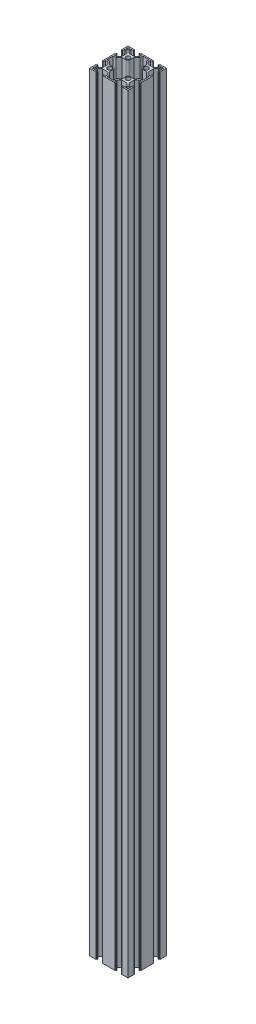
from build123d import *

# Parameters (mm, degrees)
SKETCH1_W                = 60
SKETCH1_H                = 60
BOSS_EXTRUDE1_DEPTH      = 1200
CUT_EXTRUDE1_DEPTH       = 1201.749765771
CIRPATTERN1_COUNT        = 4
CIRPATTERN1_COPY_1_DEPTH = 1201.749765771
CIRPATTERN1_COPY_2_DEPTH = 1201.749765771
CIRPATTERN1_COPY_3_DEPTH = 1201.749765771
SKETCH4_R                = 3.4
CUT_EXTRUDE2_DEPTH       = 1201.749765771
FILLET1_R                = 0.2
FILLET2_R                = 0.2
FILLET3_R                = 0.2
FILLET4_R                = 0.2


with BuildPart() as part:
    # Sketch1 → Boss-Extrude1 (new body)
    with BuildSketch(Plane(origin=(0, 0, 0), x_dir=(1, 0, 0), z_dir=(0, 1, 0))):
        Rectangle(SKETCH1_W, SKETCH1_H)
        Polygon((-23.05, -28), (-6.95, -28), (-6.95, -24.4), (-10.615, -20.8), (-19.385, -20.8), (-23.05, -24.4), align=None, mode=Mode.SUBTRACT)
        Polygon((10.615, -20.8), (19.385, -20.8), (23.05, -24.4), (23.05, -28), (6.95, -28), (6.95, -24.4), align=None, mode=Mode.SUBTRACT)
        Polygon((19.385, 20.8), (23.05, 24.4), (23.05, 28), (6.95, 28), (6.95, 24.4), (10.615, 20.8), align=None, mode=Mode.SUBTRACT)
        Polygon((-23.05, 24.4), (-23.05, 28), (-6.95, 28), (-6.95, 24.4), (-10.615, 20.8), (-19.385, 20.8), align=None, mode=Mode.SUBTRACT)
        Polygon((-20.8, 19.385), (-24.4, 23.05), (-28, 23.05), (-28, 6.95), (-24.4, 6.95), (-20.8, 10.615), align=None, mode=Mode.SUBTRACT)
        Polygon((-24.4, -23.05), (-28, -23.05), (-28, -6.95), (-24.4, -6.95), (-20.8, -10.615), (-20.8, -19.385), align=None, mode=Mode.SUBTRACT)
        Polygon((20.8, -19.385), (24.4, -23.05), (28, -23.05), (28, -6.95), (24.4, -6.95), (20.8, -10.615), align=None, mode=Mode.SUBTRACT)
        Polygon((24.4, 23.05), (28, 23.05), (28, 6.95), (24.4, 6.95), (20.8, 10.615), (20.8, 19.385), align=None, mode=Mode.SUBTRACT)
    extrude(amount=BOSS_EXTRUDE1_DEPTH)

    # Sketch2 → Cut-Extrude1 (cut, through all)
    with BuildSketch(Plane(origin=(0, 1200, 0), x_dir=(1, 0, 0), z_dir=(0, 1, 0))):
        Polygon((-19.1, -28), (-19.1, -29), (-20.1, -29), (-20.1, -30), (-9.9, -30), (-9.9, -29), (-10.9, -29), (-10.9, -28), align=None)
    cut_extrude1 = extrude(amount=-CUT_EXTRUDE1_DEPTH, mode=Mode.SUBTRACT)

    # Mirror1: Cut-Extrude1 across plane
    add(cut_extrude1.mirror(Plane(origin=(0, 0, 0), x_dir=(0, 0, 1), z_dir=(1, 0, 0))), mode=Mode.SUBTRACT)

    # CirPattern1: Cut-Extrude1 ×4 about axis
    cirpattern1_axis = Axis((0, 1050, 0), (0, -1, 0))
    for i in range(1, CIRPATTERN1_COUNT):
        add(cut_extrude1.rotate(cirpattern1_axis, i * 360 / CIRPATTERN1_COUNT), mode=Mode.SUBTRACT)

    # CirPattern1 copy 1 sketch → CirPattern1 copy 1 (cut, through all)
    with BuildSketch(Plane(origin=(0, 1200, 0), x_dir=(0, 0, -1), z_dir=(0, 1, 0))):
        Polygon((-19.1, 28), (-19.1, 29), (-20.1, 29), (-20.1, 30), (-9.9, 30), (-9.9, 29), (-10.9, 29), (-10.9, 28), align=None)
    extrude(amount=-CIRPATTERN1_COPY_1_DEPTH, mode=Mode.SUBTRACT)

    # CirPattern1 copy 2 sketch → CirPattern1 copy 2 (cut, through all)
    with BuildSketch(Plane(origin=(0, 1200, 0), x_dir=(1, 0, 0), z_dir=(0, 1, 0))):
        Polygon((-19.1, 28), (-19.1, 29), (-20.1, 29), (-20.1, 30), (-9.9, 30), (-9.9, 29), (-10.9, 29), (-10.9, 28), align=None)
    extrude(amount=-CIRPATTERN1_COPY_2_DEPTH, mode=Mode.SUBTRACT)

    # CirPattern1 copy 3 sketch → CirPattern1 copy 3 (cut, through all)
    with BuildSketch(Plane.ZX.offset(1200)):
        Polygon((-19.1, 28), (-19.1, 29), (-20.1, 29), (-20.1, 30), (-9.9, 30), (-9.9, 29), (-10.9, 29), (-10.9, 28), align=None)
    extrude(amount=-CIRPATTERN1_COPY_3_DEPTH, mode=Mode.SUBTRACT)

    # Sketch4 → Cut-Extrude2 (cut, through all)
    with BuildSketch(Plane(origin=(0, 1200, 0), x_dir=(1, 0, 0), z_dir=(0, 1, 0))):
        with BuildLine():
            Line((-13.197035349, 9.797035349), (-18.8, 9.797035349))
            Line((-18.8, 9.797035349), (-23.561071557, 4.95))
            Line((-23.561071557, 4.95), (-28, 4.95))
            Line((-28, 4.95), (-28, -4.95))
            Line((-28, -4.95), (-23.561071557, -4.95))
            Line((-23.561071557, -4.95), (-18.8, -9.797035349))
            Line((-18.8, -9.797035349), (-13.197035349, -9.797035349))
            ThreePointArc((-13.197035349, -9.797035349), (-10.792872293, -10.792872293), (-9.797035349, -13.197035349))
            Line((-9.797035349, -13.197035349), (-9.797035349, -18.8))
            Line((-9.797035349, -18.8), (-4.95, -23.561071557))
            Line((-4.95, -23.561071557), (-4.95, -28))
            Line((-4.95, -28), (4.95, -28))
            Line((4.95, -28), (4.95, -23.561071557))
            Line((4.95, -23.561071557), (9.797035349, -18.8))
            Line((9.797035349, -18.8), (9.797035349, -13.197035349))
            ThreePointArc((9.797035349, -13.197035349), (10.792872293, -10.792872293), (13.197035349, -9.797035349))
            Line((13.197035349, -9.797035349), (18.8, -9.797035349))
            Line((18.8, -9.797035349), (23.561071557, -4.95))
            Line((23.561071557, -4.95), (28, -4.95))
            Line((28, -4.95), (28, 4.95))
            Line((28, 4.95), (23.561071557, 4.95))
            Line((23.561071557, 4.95), (18.8, 9.797035349))
            Line((18.8, 9.797035349), (13.197035349, 9.797035349))
            ThreePointArc((13.197035349, 9.797035349), (10.792872293, 10.792872293), (9.797035349, 13.197035349))
            Line((9.797035349, 13.197035349), (9.797035349, 18.8))
            Line((9.797035349, 18.8), (4.95, 23.561071557))
            Line((4.95, 23.561071557), (4.95, 28))
            Line((4.95, 28), (-4.95, 28))
            Line((-4.95, 28), (-4.95, 23.561071557))
            Line((-4.95, 23.561071557), (-9.797035349, 18.8))
            Line((-9.797035349, 18.8), (-9.797035349, 13.197035349))
            ThreePointArc((-9.797035349, 13.197035349), (-10.792872293, 10.792872293), (-13.197035349, 9.797035349))
        make_face()
        with BuildLine():
            ThreePointArc((-28, -27.5), (-27.853553391, -27.853553391), (-27.5, -28))
            Line((-27.5, -28), (-24.9, -28))
            ThreePointArc((-24.9, -28), (-24.546446609, -27.853553391), (-24.4, -27.5))
            Line((-24.4, -27.5), (-24.4, -24.9))
            ThreePointArc((-24.4, -24.9), (-24.546446609, -24.546446609), (-24.9, -24.4))
            Line((-24.9, -24.4), (-27.5, -24.4))
            ThreePointArc((-27.5, -24.4), (-27.853553391, -24.546446609), (-28, -24.9))
            Line((-28, -24.9), (-28, -27.5))
        make_face()
        with BuildLine():
            ThreePointArc((24.4, -27.5), (24.546446609, -27.853553391), (24.9, -28))
            Line((24.9, -28), (27.5, -28))
            ThreePointArc((27.5, -28), (27.853553391, -27.853553391), (28, -27.5))
            Line((28, -27.5), (28, -24.9))
            ThreePointArc((28, -24.9), (27.853553391, -24.546446609), (27.5, -24.4))
            Line((27.5, -24.4), (24.9, -24.4))
            ThreePointArc((24.9, -24.4), (24.546446609, -24.546446609), (24.4, -24.9))
            Line((24.4, -24.9), (24.4, -27.5))
        make_face()
        with BuildLine():
            ThreePointArc((-27.5, 28), (-27.853553391, 27.853553391), (-28, 27.5))
            Line((-28, 27.5), (-28, 24.9))
            ThreePointArc((-28, 24.9), (-27.853553391, 24.546446609), (-27.5, 24.4))
            Line((-27.5, 24.4), (-24.9, 24.4))
            ThreePointArc((-24.9, 24.4), (-24.546446609, 24.546446609), (-24.4, 24.9))
            Line((-24.4, 24.9), (-24.4, 27.5))
            ThreePointArc((-24.4, 27.5), (-24.546446609, 27.853553391), (-24.9, 28))
            Line((-24.9, 28), (-27.5, 28))
        make_face()
        with BuildLine():
            ThreePointArc((28, 27.5), (27.853553391, 27.853553391), (27.5, 28))
            Line((27.5, 28), (24.9, 28))
            ThreePointArc((24.9, 28), (24.546446609, 27.853553391), (24.4, 27.5))
            Line((24.4, 27.5), (24.4, 24.9))
            ThreePointArc((24.4, 24.9), (24.546446609, 24.546446609), (24.9, 24.4))
            Line((24.9, 24.4), (27.5, 24.4))
            ThreePointArc((27.5, 24.4), (27.853553391, 24.546446609), (28, 24.9))
            Line((28, 24.9), (28, 27.5))
        make_face()
        with Locations((14.298517674, 14.298517674)):
            Circle(SKETCH4_R)
        with Locations((14.298517674, -14.298517674)):
            Circle(SKETCH4_R)
        with Locations((-14.298517674, -14.298517674)):
            Circle(SKETCH4_R)
        with Locations((-14.298517674, 14.298517674)):
            Circle(SKETCH4_R)
    extrude(amount=-CUT_EXTRUDE2_DEPTH, mode=Mode.SUBTRACT)

    # Fillet1
    fillet1_edges = [part.edges().sort_by_distance(p)[0] for p in [
        (28, 600, -19.1),
        (30, 600, -20.1),
        (29, 600, -20.1),
        (29, 600, -19.1),
        (28, 600, 10.9),
        (29, 600, 9.9),
        (28, 600, 19.1),
        (29, 600, 20.1),
        (30, 600, 20.1),
        (29, 600, 19.1),
        (29, 600, 10.9),
        (30, 600, 9.9),
        (30, 600, -9.9),
        (29, 600, -9.9),
        (29, 600, -10.9),
        (28, 600, -10.9),
    ]]
    fillet(fillet1_edges, radius=FILLET1_R)

    # Fillet2
    fillet2_edges = [part.edges().sort_by_distance(p)[0] for p in [
        (-20.1, 0, -29.5),
        (-20.1, 1200, -29.5),
        (-20.1, 600, -29),
        (-19.6, 0, -29),
        (-19.1, 600, -29),
        (-19.6, 1200, -29),
        (-9.9, 600, -30),
        (-10.9, 600, -28),
        (-10.9, 600, -29),
        (-9.9, 600, -29),
        (19.1, 600, -28),
        (19.1, 600, -29),
        (20.1, 600, -29),
        (20.1, 600, -30),
        (10.9, 600, -28),
        (10.9, 600, -29),
        (9.9, 600, -29),
        (9.9, 600, -30),
        (-19.1, 600, -28),
        (-20.1, 600, -30),
    ]]
    fillet(fillet2_edges, radius=FILLET2_R)

    # Fillet3
    fillet3_edges = [part.edges().sort_by_distance(p)[0] for p in [
        (-29, 600, 9.9),
        (-29, 600, -20.1),
        (-30, 600, -20.1),
        (-29, 600, -19.1),
        (-28, 600, -10.9),
        (-29, 600, -10.9),
        (-29, 600, -9.9),
        (-30, 600, -9.9),
        (-29, 600, 10.9),
        (-30, 600, 9.9),
        (-28, 600, 19.1),
        (-29, 600, 19.1),
        (-29, 600, 20.1),
        (-30, 600, 20.1),
    ]]
    fillet(fillet3_edges, radius=FILLET3_R)

    # Fillet4
    fillet4_edges = [part.edges().sort_by_distance(p)[0] for p in [
        (-19.1, 600, 28),
        (10.9, 600, 28),
        (19.1, 600, 28),
        (20.1, 600, 29),
        (-10.9, 600, 28),
        (-9.9, 600, 29),
        (9.9, 600, 29),
        (-20.1, 600, 29),
        (19.1, 600, 29),
        (20.1, 600, 30),
        (10.9, 600, 29),
        (9.9, 600, 30),
        (-9.9, 600, 30),
        (-10.9, 600, 29),
        (-19.1, 600, 29),
        (-20.1, 600, 30),
    ]]
    fillet(fillet4_edges, radius=FILLET4_R)


solid = part.part
